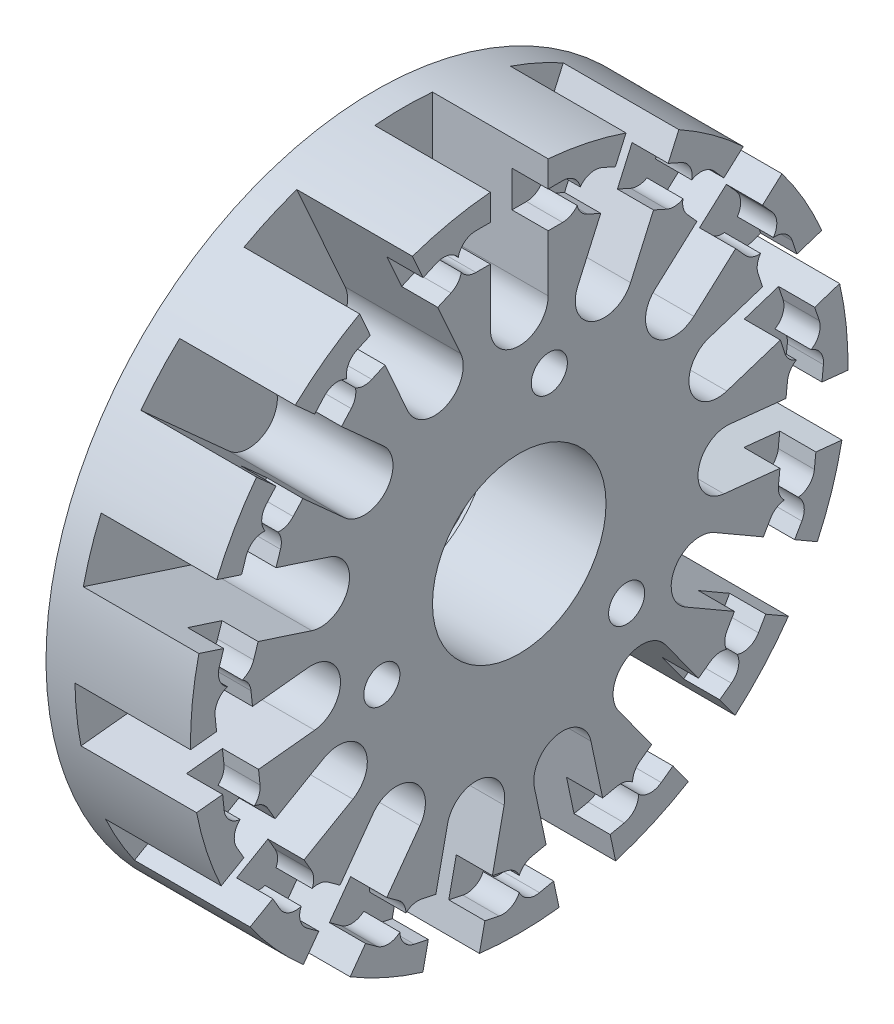
from build123d import *

# Parameters (mm, degrees)
SKETCH1_R           = 22.75
SKETCH1_R_2         = 6.005
BOSS_EXTRUDE1_DEPTH = 10
CUT_EXTRUDE1_DEPTH  = 8
CUT_EXTRUDE2_DEPTH  = 2.5
CIRPATTERN1_COUNT   = 15
CIRPATTERN2_COUNT   = 3
SKETCH7_R           = 18.75
CUT_EXTRUDE3_DEPTH  = 1
SKETCH8_R           = 6.8
CUT_EXTRUDE4_DEPTH  = 0.8
CIRPATTERN3_COUNT   = 5


with BuildPart() as part:
    # Sketch1 → Boss-Extrude1 (new body)
    with BuildSketch(Plane(origin=(0, 0, 0), x_dir=(0, 0, -1), z_dir=(1, 0, 0))):
        Circle(SKETCH1_R)
        Circle(SKETCH1_R_2, mode=Mode.SUBTRACT)
    extrude(amount=BOSS_EXTRUDE1_DEPTH)

    # Sketch2 → Cut-Extrude1 (cut)
    with BuildSketch(Plane(origin=(10, 0, 0), x_dir=(0, 0, -1), z_dir=(1, 0, 0))):
        with BuildLine():
            Line((-2, 22.75), (2, 22.75))
            Line((2, 22.75), (2, 14.45))
            ThreePointArc((2, 14.45), (0, 12.45), (-2, 14.45))
            Line((-2, 14.45), (-2, 22.75))
        make_face()
    cut_extrude1 = extrude(amount=-CUT_EXTRUDE1_DEPTH, mode=Mode.SUBTRACT)

    # Sketch3 → Cut-Extrude2 (cut)
    with BuildSketch(Plane(origin=(10, 0, 0), x_dir=(0, 0, -1), z_dir=(1, 0, 0))):
        with BuildLine():
            Line((-3, 20.85), (3, 20.85))
            ThreePointArc((3, 20.85), (4.25, 19.6), (3, 18.35))
            Line((3, 18.35), (-3, 18.35))
            ThreePointArc((-3, 18.35), (-4.25, 19.6), (-3, 20.85))
        make_face()
    cut_extrude2 = extrude(amount=-CUT_EXTRUDE2_DEPTH, mode=Mode.SUBTRACT)

    # CirPattern1: Cut-Extrude1, Cut-Extrude2 ×15 about axis
    cirpattern1_axis = Axis((0, 0, 0), (1, 0, 0))
    for i in range(1, CIRPATTERN1_COUNT):
        add(cut_extrude1.rotate(cirpattern1_axis, i * 360 / CIRPATTERN1_COUNT), mode=Mode.SUBTRACT)
        add(cut_extrude2.rotate(cirpattern1_axis, i * 360 / CIRPATTERN1_COUNT), mode=Mode.SUBTRACT)

    # Sketch5 → Tap Drill for M3x0.5 Tap1 (revolve, cut)
    with BuildSketch(Plane(origin=(10, 9.781476007, -2.079116908), x_dir=(0, 0, -1), z_dir=(0, 1, 0))):
        Polygon((0, 0), (0, 7.751075774), (1.25, 7), (1.25, 0), align=None)
    tap_drill_for_m3x0_5_tap1 = revolve(axis=Axis((16.35, 9.781476007, -2.079116908), (-1, 0, 0)), mode=Mode.SUBTRACT)

    # CirPattern2: Tap Drill for M3x0.5 Tap1 ×3 about axis
    cirpattern2_axis = Axis((0, 0, 0), (1, 0, 0))
    for i in range(1, CIRPATTERN2_COUNT):
        add(tap_drill_for_m3x0_5_tap1.rotate(cirpattern2_axis, i * 360 / CIRPATTERN2_COUNT), mode=Mode.SUBTRACT)

    # Sketch7 → Cut-Extrude3 (cut)
    with BuildSketch(Plane.ZY):
        Circle(SKETCH7_R)
    extrude(amount=-CUT_EXTRUDE3_DEPTH, mode=Mode.SUBTRACT)

    # Sketch8 → Cut-Extrude4 (cut)
    with BuildSketch(Plane.ZY.offset(-1)):
        Circle(SKETCH8_R)
    extrude(amount=-CUT_EXTRUDE4_DEPTH, mode=Mode.SUBTRACT)

    # Sketch9 → Tap Drill for M2x0.4 Tap1 (revolve, cut)
    with BuildSketch(Plane(origin=(0, 20.296562715, -4.314167584), x_dir=(0, 0, 1), z_dir=(0, 1, 0))):
        Polygon((0, 0), (0, 5.980688495), (0.8, 5.5), (0.8, 0), align=None)
    tap_drill_for_m2x0_4_tap1 = revolve(axis=Axis((-6.35, 20.296562715, -4.314167584), (1, 0, 0)), mode=Mode.SUBTRACT)

    # CirPattern3: Tap Drill for M2x0.4 Tap1 ×5 about axis
    cirpattern3_axis = Axis((0, 0, 0), (1, 0, 0))
    for i in range(1, CIRPATTERN3_COUNT):
        add(tap_drill_for_m2x0_4_tap1.rotate(cirpattern3_axis, i * 360 / CIRPATTERN3_COUNT), mode=Mode.SUBTRACT)


solid = part.part
